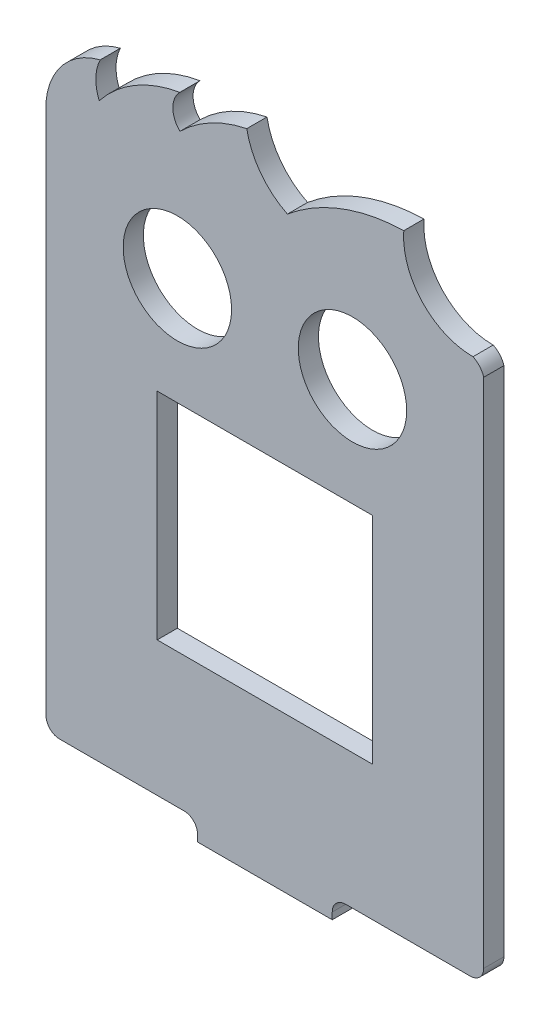
from build123d import *

# Parameters (mm, degrees)
MODEL_R                 = 8.05
MODEL_W                 = 32
MODEL_H                 = 32
SALIENTE_EXTRUIR1_DEPTH = 3
CROQUIS2_W              = 20
CROQUIS2_H              = 3.368375984
SALIENTE_EXTRUIR2_DEPTH = 8
CROQUIS3_R              = 1.5
CORTAR_EXTRUIR1_DEPTH   = 4
REDONDEO1_R             = 2
CROQUIS4_R              = 2.25
CORTAR_EXTRUIR2_DEPTH   = 1


with BuildPart() as part:
    # Model → Saliente-Extruir1 (new body)
    with BuildSketch(Plane.XY):
        with BuildLine():
            Line((89.198959582, -53.020997464), (70.698959583, -53.020997464))
            ThreePointArc((70.698959583, -53.020997464), (69.28474602, -53.606783901), (68.698959582, -55.020997464))
            Line((68.698959582, -55.020997464), (68.698959582, -56.020997464))
            Line((68.698959582, -56.020997464), (48.698959582, -56.020997464))
            Line((48.698959582, -56.020997464), (48.698959583, -55.020997464))
            ThreePointArc((48.698959583, -55.020997464), (48.113173145, -53.606783901), (46.698959582, -53.020997464))
            Line((46.698959582, -53.020997464), (28.198959582, -53.020997464))
            ThreePointArc((28.198959582, -53.020997464), (26.78474602, -52.435211026), (26.198959582, -51.020997464))
            Line((26.198959582, -51.020997464), (26.198959582, 28.005161342))
            ThreePointArc((26.198959582, 28.005161342), (28.72866076, 33.955350752), (34.23516159, 37.343947904))
            ThreePointArc((34.23516159, 37.343947904), (33.593436695, 34.698271666), (34.088137303, 32.021205191))
            ThreePointArc((34.088137303, 32.021205191), (39.416934224, 36.659890309), (46.05573433, 39.07646007))
            ThreePointArc((46.05573433, 39.07646007), (45.031738366, 36.571712032), (46.078788199, 34.076513218))
            ThreePointArc((46.078788199, 34.076513218), (50.656295588, 37.451644327), (56.004342405, 39.386451589))
            ThreePointArc((56.004342405, 39.386451589), (58.081757107, 34.687776201), (62.041164818, 31.41420127))
            ThreePointArc((62.041164818, 31.41420127), (70.12810034, 36.137425043), (79.321724733, 37.92198087))
            ThreePointArc((79.321724733, 37.92198087), (82.046795326, 30.144055291), (89.601066614, 26.849344169))
            ThreePointArc((89.601066614, 26.849344169), (90.596172101, 26.096573111), (91.198959583, 25.004077597))
            Line((91.198959583, 25.004077597), (91.198959583, -51.020997464))
            ThreePointArc((91.198959583, -51.020997464), (90.613173145, -52.435211026), (89.198959582, -53.020997464))
        make_face()
        with Locations((71.698959582, 14.979002536)):
            Circle(MODEL_R, mode=Mode.SUBTRACT)
        with Locations((45.698959583, 14.979002536)):
            Circle(MODEL_R, mode=Mode.SUBTRACT)
        with Locations((58.698959582, -17.020997464)):
            Rectangle(MODEL_W, MODEL_H, mode=Mode.SUBTRACT)
    extrude(amount=-SALIENTE_EXTRUIR1_DEPTH)

    # Croquis2 → Saliente-Extruir2 (add)
    with BuildSketch(Plane(origin=(0, 0, -3), x_dir=(-1, 0, 0), z_dir=(0, 0, -1))):
        with Locations((-58.698959582, -54.336809472)):
            Rectangle(CROQUIS2_W, CROQUIS2_H)
    extrude(amount=SALIENTE_EXTRUIR2_DEPTH)

    # Croquis3 → Cortar-Extruir1 (cut)
    with BuildSketch(Plane(origin=(0, -52.65262148, 0), x_dir=(1, 0, 0), z_dir=(0, 1, 0))):
        with Locations((64.698959582, 6.5)):
            Circle(CROQUIS3_R)
        with Locations((52.698959582, 6.5)):
            Circle(CROQUIS3_R)
    extrude(amount=-CORTAR_EXTRUIR1_DEPTH, mode=Mode.SUBTRACT)

    # Redondeo1
    redondeo1_edges = [part.edges().sort_by_distance(p)[0] for p in [
        (48.698959582, -54.336809472, -11),
        (68.698959582, -54.336809472, -11),
    ]]
    fillet(redondeo1_edges, radius=REDONDEO1_R)

    # Croquis4 → Cortar-Extruir2 (cut)
    with BuildSketch(Plane(origin=(0, -52.65262148, 0), x_dir=(1, 0, 0), z_dir=(0, 1, 0))):
        with Locations((52.698959582, 6.5)):
            Circle(CROQUIS4_R)
        with Locations((64.698959582, 6.5)):
            Circle(CROQUIS4_R)
    extrude(amount=-CORTAR_EXTRUIR2_DEPTH, mode=Mode.SUBTRACT)


solid = part.part
